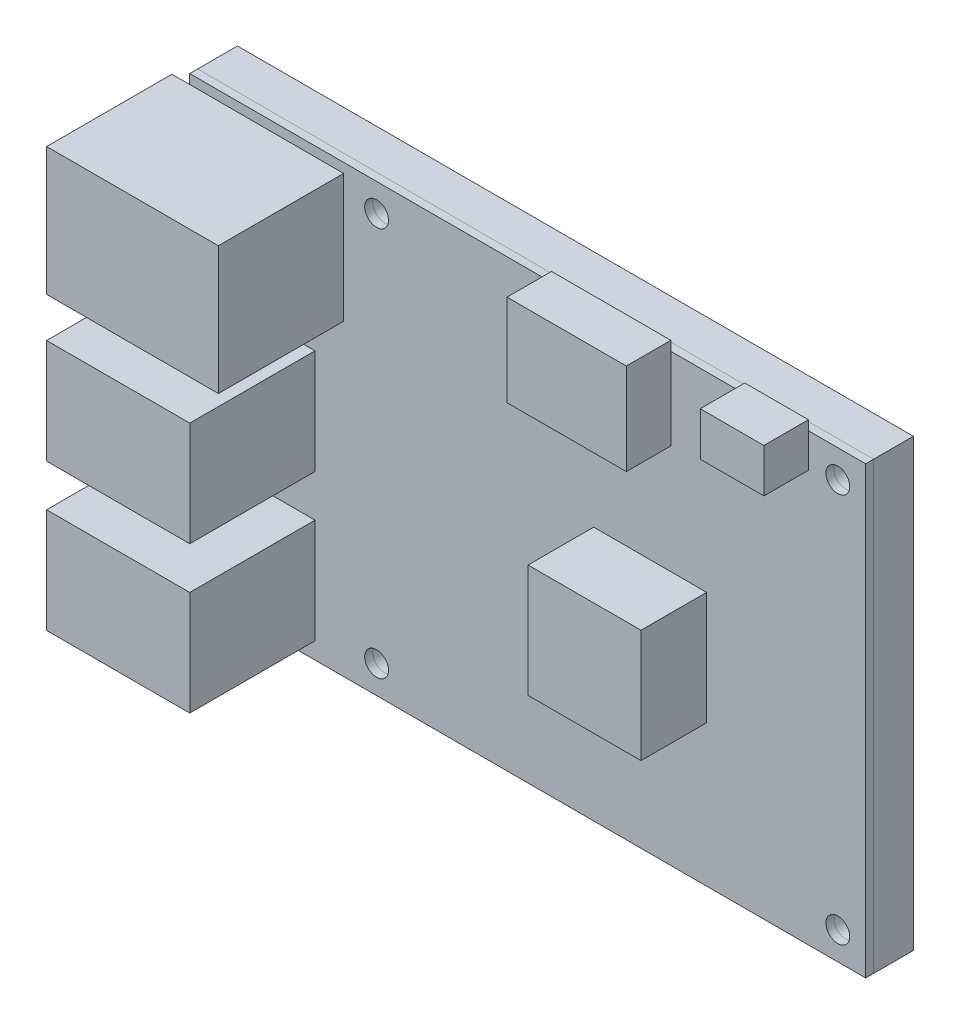
from build123d import *

# Parameters (mm, degrees)
SKETCH1_W           = 85
SKETCH1_H           = 56
SKETCH1_R           = 1.5
BOSS_EXTRUDE1_DEPTH = 1
SKETCH1_2_W         = 85
SKETCH1_2_H         = 56
SKETCH1_2_R         = 1.5
BOSS_EXTRUDE2_DEPTH = 5
SKETCH3_W           = 14.2
SKETCH3_H           = 14.2
BOSS_EXTRUDE3_DEPTH = 8.25
SKETCH4_W           = 18
SKETCH4_H           = 13.14
SKETCH4_W_2         = 21.6
SKETCH4_H_2         = 16.1
BOSS_EXTRUDE4_DEPTH = 15.75
SKETCH5_W           = 15
SKETCH5_H           = 11.5
SKETCH5_W_2         = 8
SKETCH5_H_2         = 5.5
BOSS_EXTRUDE5_DEPTH = 5.6


with BuildPart() as part:
    # Sketch1 → Boss-Extrude1 (new body)
    with BuildSketch(Plane.XY):
        with Locations((6.081574074, 9.647501164)):
            Rectangle(SKETCH1_W, SKETCH1_H)
        with Locations((-12.918426004, 34.147501164)):
            Circle(SKETCH1_R, mode=Mode.SUBTRACT)
        with Locations((-12.918426004, -14.852498836)):
            Circle(SKETCH1_R, mode=Mode.SUBTRACT)
        with Locations((45.081574074, 34.147501164)):
            Circle(SKETCH1_R, mode=Mode.SUBTRACT)
        with Locations((45.081574074, -14.852498836)):
            Circle(SKETCH1_R, mode=Mode.SUBTRACT)
    extrude(amount=BOSS_EXTRUDE1_DEPTH)

    # Sketch3 → Boss-Extrude3 (add)
    with BuildSketch(Plane.XY.offset(1)):
        with Locations((21.481574074, 6.547501164)):
            Rectangle(SKETCH3_W, SKETCH3_H)
    extrude(amount=BOSS_EXTRUDE3_DEPTH)

    # Sketch4 → Boss-Extrude4 (add)
    with BuildSketch(Plane.XY.offset(1)):
        with Locations((-29.667902016, 8.757501164)):
            Rectangle(SKETCH4_W, SKETCH4_H)
        with Locations((-29.667902016, -9.682498836)):
            Rectangle(SKETCH4_W, SKETCH4_H)
        with Locations((-27.867902016, 28.397501164)):
            Rectangle(SKETCH4_W_2, SKETCH4_H_2)
    extrude(amount=BOSS_EXTRUDE4_DEPTH)

    # Sketch5 → Boss-Extrude5 (add)
    with BuildSketch(Plane.XY.offset(1)):
        with Locations((16.581574074, 33.097501164)):
            Rectangle(SKETCH5_W, SKETCH5_H)
        with Locations((37.381574074, 36.097501164)):
            Rectangle(SKETCH5_W_2, SKETCH5_H_2)
    extrude(amount=BOSS_EXTRUDE5_DEPTH)


with BuildPart() as body_2:
    # Sketch1_2 → Boss-Extrude2 (new body)
    with BuildSketch(Plane.XY):
        with Locations((6.081574074, 9.647501164)):
            Rectangle(SKETCH1_2_W, SKETCH1_2_H)
        with Locations((-12.918426004, 34.147501164)):
            Circle(SKETCH1_2_R, mode=Mode.SUBTRACT)
        with Locations((-12.918426004, -14.852498836)):
            Circle(SKETCH1_2_R, mode=Mode.SUBTRACT)
        with Locations((45.081574074, 34.147501164)):
            Circle(SKETCH1_2_R, mode=Mode.SUBTRACT)
        with Locations((45.081574074, -14.852498836)):
            Circle(SKETCH1_2_R, mode=Mode.SUBTRACT)
    extrude(amount=-BOSS_EXTRUDE2_DEPTH)


solid = Compound([part.part, body_2.part])
